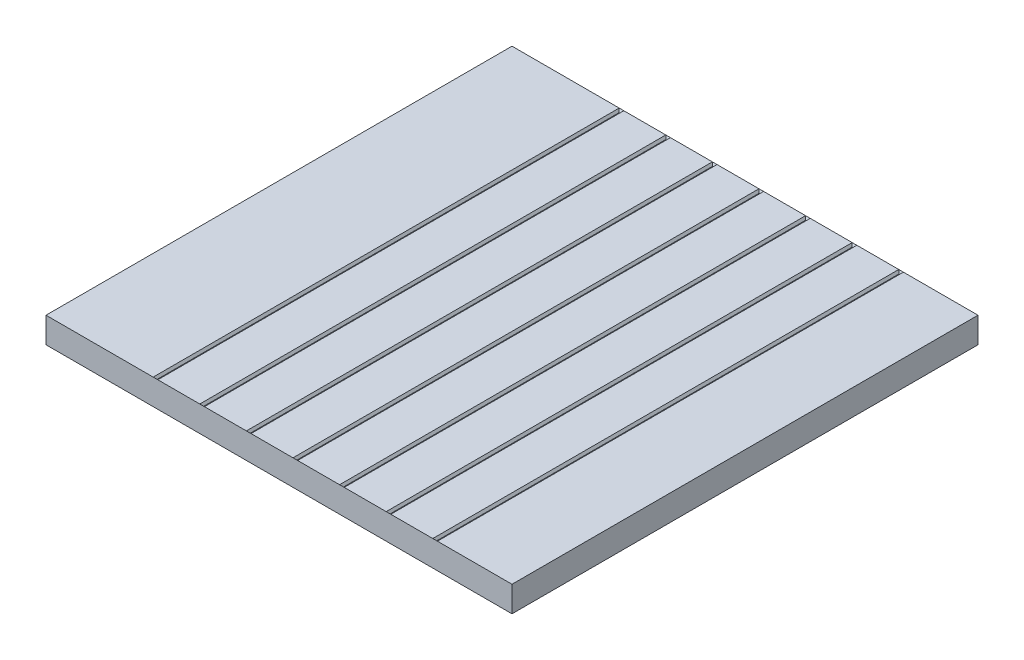
from build123d import *

# Parameters (mm, degrees)
SKETCH1_W           = 20
SKETCH1_H           = 20
BOSS_EXTRUDE2_DEPTH = 1.1
SKETCH2_W           = 0.2
SKETCH2_H           = 20
CUT_EXTRUDE1_DEPTH  = 0.1
CUT_EXTRUDE1_TAPER  = 35


with BuildPart() as part:
    # Sketch1 → Boss-Extrude2 (new body)
    with BuildSketch(Plane(origin=(0, 0, 0), x_dir=(1, 0, 0), z_dir=(0, 1, 0))):
        with Locations((10, 10)):
            Rectangle(SKETCH1_W, SKETCH1_H)
    extrude(amount=BOSS_EXTRUDE2_DEPTH)

    # Sketch2 → Cut-Extrude1 (cut)
    with BuildSketch(Plane(origin=(0, 1.1, 0), x_dir=(1, 0, 0), z_dir=(0, 1, 0))):
        with Locations((16.7, 10)):
            Rectangle(SKETCH2_W, SKETCH2_H)
        with Locations((14.7, 10)):
            Rectangle(SKETCH2_W, SKETCH2_H)
        with Locations((12.7, 10)):
            Rectangle(SKETCH2_W, SKETCH2_H)
        with Locations((10.7, 10)):
            Rectangle(SKETCH2_W, SKETCH2_H)
        with Locations((8.7, 10)):
            Rectangle(SKETCH2_W, SKETCH2_H)
        with Locations((6.7, 10)):
            Rectangle(SKETCH2_W, SKETCH2_H)
        with Locations((4.7, 10)):
            Rectangle(SKETCH2_W, SKETCH2_H)
    extrude(amount=-CUT_EXTRUDE1_DEPTH, taper=CUT_EXTRUDE1_TAPER, mode=Mode.SUBTRACT)


solid = part.part
